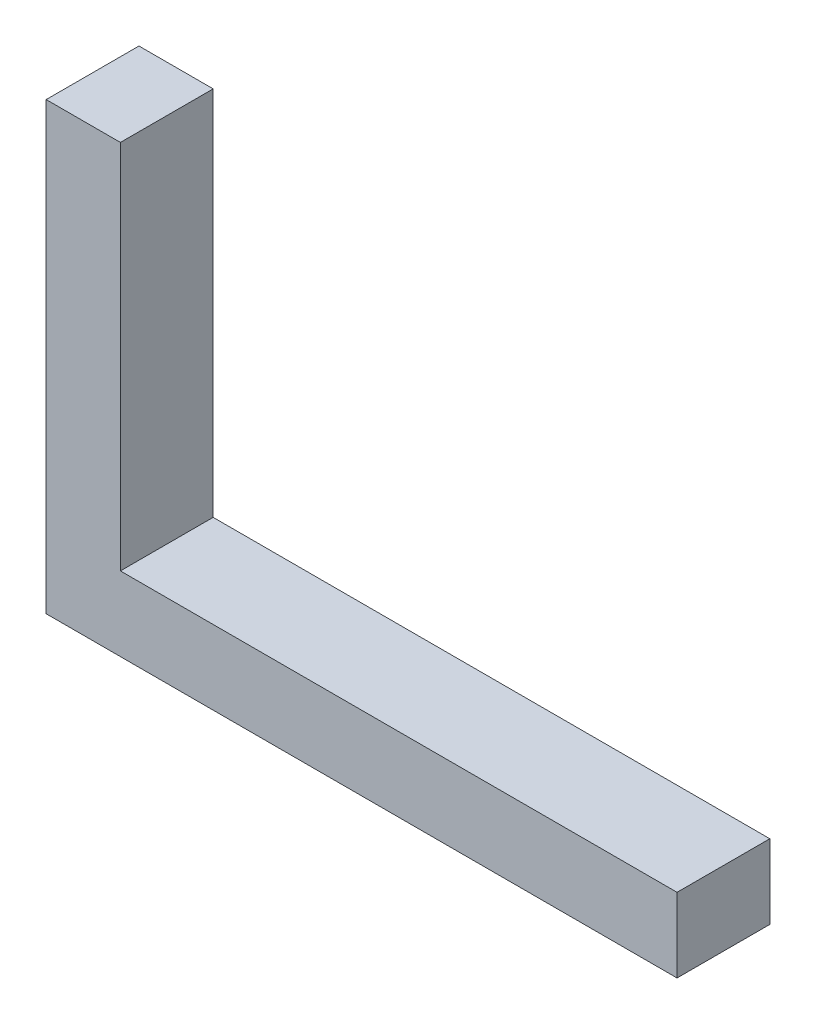
from build123d import *

# Parameters (mm, degrees)
BOSS_EXTRUDE1_DEPTH = 5


with BuildPart() as part:
    # Sketch1 → Boss-Extrude1 (new body)
    with BuildSketch(Plane.XY):
        Polygon((0, 24), (0, 0), (34, 0), (34, 4), (4, 4), (4, 24), align=None)
    extrude(amount=BOSS_EXTRUDE1_DEPTH)


solid = part.part
